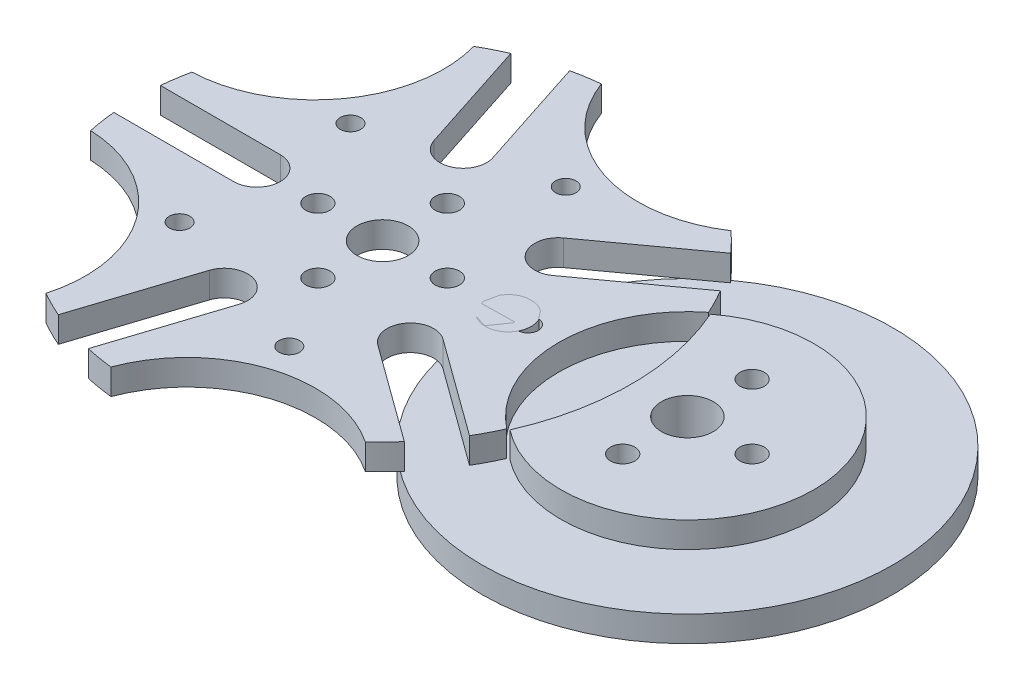
from build123d import *

# Parameters (mm, degrees)
DRIVEWHEEL_TOP_DEPTH            = 3.175
SKETCH13_R                      = 25.4
SKETCH13_R_2                    = 2.8321
WHEEL_BOTTOM_DEPTH              = 3.175
SKETCH13_4_R                    = 2.8321
PEG_DEPTH                       = 3.175
PEG_DEPTH_BACK                  = 3.175
SKETCH14_R                      = 3.2131
DRIVER_CENTER_HOLE_DEPTH        = 4.175
DRIVER_CENTER_HOLE_DEPTH_BACK   = 4.175
SKETCH16_R                      = 1.5
DRIVER_COUPLER_HOLES_DEPTH      = 7.35
MAIN_CIRCLES_R                  = 30.48
WHEELBASE_DEPTH                 = 3.175
SLOT_CUT_DEPTH                  = 4.175
SKETCH17_R                      = 3.175
WHEEL_CENTER_HOLE_DEPTH         = 7.35
DRIVEWHEEL_CONSTRUCTION_LINES_R = 15.899413966
DIVOT_DEPTH                     = 4.175
CIRCPATTERN_SLOT_COUNT          = 5
CIRCPATTERN_DIVOTS_COUNT        = 5
SKETCH18_R                      = 1.5
WHEEL_COUPLER_HOLES_DEPTH       = 7.35
SKETCH20_R                      = 1.27
CUT_EXTRUDE1_DEPTH              = 7.35
CIRPATTERN1_COUNT               = 5


with BuildPart() as part:
    # Sketch8 → drivewheel top (new body)
    with BuildSketch(Plane(origin=(0, 0, 0), x_dir=(1, 0, 0), z_dir=(0, 1, 0))):
        with BuildLine():
            ThreePointArc((28.124912082, 12.392258729), (30.734, 0), (28.124912082, -12.392258729))
            ThreePointArc((28.124912082, -12.392258729), (53.32076592, 0), (28.124912082, 12.392258729))
        make_face()
    extrude(amount=DRIVEWHEEL_TOP_DEPTH)


with BuildPart() as body_2:
    # Sketch13 → wheel bottom (new body)
    with BuildSketch(Plane(origin=(0, 0, 0), x_dir=(1, 0, 0), z_dir=(0, 1, 0))):
        with Locations((37.675351954, 0)):
            Circle(SKETCH13_R)
        with Locations((15.530335701, 0)):
            Circle(SKETCH13_R_2, mode=Mode.SUBTRACT)
    extrude(amount=-WHEEL_BOTTOM_DEPTH)

    # Sketch13_4 → peg (add, two sides)
    with BuildSketch(Plane(origin=(0, 0, 0), x_dir=(1, 0, 0), z_dir=(0, 1, 0))) as peg_sk:
        with Locations((15.530335701, 0)):
            Circle(SKETCH13_4_R)
    extrude(amount=PEG_DEPTH)
    extrude(peg_sk.sketch, amount=-PEG_DEPTH_BACK)

    # Combine1: union part
    add(part.part)

    # Sketch14 → driver center hole (cut, two sides)
    with BuildSketch(Plane(origin=(0, 0, 0), x_dir=(1, 0, 0), z_dir=(0, 1, 0))) as driver_center_hole_sk:
        with Locations((37.675351954, 0)):
            Circle(SKETCH14_R)
    extrude(amount=DRIVER_CENTER_HOLE_DEPTH, mode=Mode.SUBTRACT)
    extrude(driver_center_hole_sk.sketch, amount=-DRIVER_CENTER_HOLE_DEPTH_BACK, mode=Mode.SUBTRACT)

    # Sketch16 → driver coupler holes (cut, through all)
    with BuildSketch(Plane(origin=(0, 3.175, 0), x_dir=(1, 0, 0), z_dir=(0, 1, 0))):
        with Locations((37.675351954, -8)):
            Circle(SKETCH16_R)
        with Locations((45.675351954, 0)):
            Circle(SKETCH16_R)
        with Locations((37.675351954, 8)):
            Circle(SKETCH16_R)
    extrude(amount=-DRIVER_COUPLER_HOLES_DEPTH, mode=Mode.SUBTRACT)


with BuildPart() as body_2_2:
    # main circles → wheelbase (new body)
    with BuildSketch(Plane(origin=(0, 0, 0), x_dir=(1, 0, 0), z_dir=(0, 1, 0))):
        Circle(MAIN_CIRCLES_R)
    extrude(amount=WHEELBASE_DEPTH)

    # slot → slot cut (cut, through all)
    with BuildSketch(Plane(origin=(0, 0, 0), x_dir=(1, 0, 0), z_dir=(0, 1, 0))):
        with BuildLine():
            Line((26.353364092, 15.583379397), (14.258831614, 6.796187195))
            ThreePointArc((14.258831614, 6.796187195), (10.231990417, 7.433976184), (10.869779406, 11.460817381))
            Line((10.869779406, 11.460817381), (22.964311885, 20.248009583))
            ThreePointArc((22.964311885, 20.248009583), (26.991153082, 19.610220594), (26.353364092, 15.583379397))
        make_face()
    slot_cut = extrude(amount=SLOT_CUT_DEPTH, mode=Mode.SUBTRACT)

    # Sketch17 → wheel center hole (cut, through all)
    with BuildSketch(Plane(origin=(0, 3.175, 0), x_dir=(1, 0, 0), z_dir=(0, 1, 0))):
        Circle(SKETCH17_R)
    extrude(amount=-WHEEL_CENTER_HOLE_DEPTH, mode=Mode.SUBTRACT)

    # drivewheel construction lines → divot (cut, through all)
    with BuildSketch(Plane(origin=(0, 0, 0), x_dir=(1, 0, 0), z_dir=(0, 1, 0))):
        with Locations((37.675351954, 0)):
            Circle(DRIVEWHEEL_CONSTRUCTION_LINES_R)
    divot = extrude(amount=DIVOT_DEPTH, mode=Mode.SUBTRACT)

    # circpattern-slot: slot cut ×5 about axis
    circpattern_slot_axis = Axis((0, 0, 0), (0, 1, 0))
    for i in range(1, CIRCPATTERN_SLOT_COUNT):
        add(slot_cut.rotate(circpattern_slot_axis, i * 360 / CIRCPATTERN_SLOT_COUNT), mode=Mode.SUBTRACT)

    # circpattern-divots: divot ×5 about axis
    circpattern_divots_axis = Axis((0, 0, 0), (0, 1, 0))
    for i in range(1, CIRCPATTERN_DIVOTS_COUNT):
        add(divot.rotate(circpattern_divots_axis, i * 360 / CIRCPATTERN_DIVOTS_COUNT), mode=Mode.SUBTRACT)

    # Sketch18 → wheel coupler holes (cut, through all)
    with BuildSketch(Plane(origin=(0, 3.175, 0), x_dir=(1, 0, 0), z_dir=(0, 1, 0))):
        with Locations((0, 8)):
            Circle(SKETCH18_R)
        with Locations((-8, 0)):
            Circle(SKETCH18_R)
        with Locations((0, -8)):
            Circle(SKETCH18_R)
        with Locations((8, 0)):
            Circle(SKETCH18_R)
    extrude(amount=-WHEEL_COUPLER_HOLES_DEPTH, mode=Mode.SUBTRACT)

    # Sketch20 → Cut-Extrude1 (cut, through all)
    with BuildSketch(Plane(origin=(0, 3.175, 0), x_dir=(1, 0, 0), z_dir=(0, 1, 0))):
        with Locations((5.551780158, 17.086622395)):
            Circle(SKETCH20_R)
    cut_extrude1 = extrude(amount=-CUT_EXTRUDE1_DEPTH, mode=Mode.SUBTRACT)

    # CirPattern1: Cut-Extrude1 ×5 about axis
    cirpattern1_axis = Axis((0, 0, 0), (0, 1, 0))
    for i in range(1, CIRPATTERN1_COUNT):
        add(cut_extrude1.rotate(cirpattern1_axis, i * 360 / CIRPATTERN1_COUNT), mode=Mode.SUBTRACT)


solid = Compound([body_2.part, body_2_2.part])
